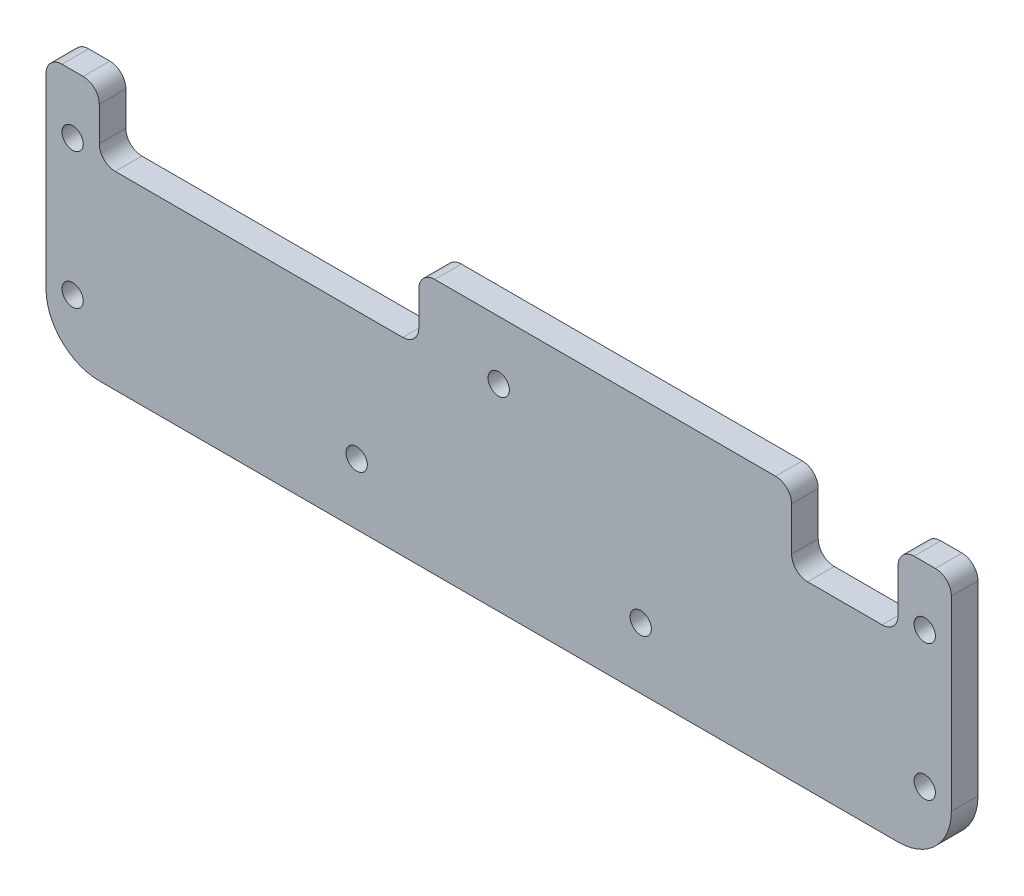
from build123d import *

# Parameters (mm, degrees)
SKETCH_1_R          = 2
EXTRUDE_1_DEPTH     = 5
SKETCH_2_W          = 60
SKETCH_2_H          = 24.578099901
SKETCH_2_W_2        = 20
SKETCH_2_H_2        = 18.209440524
CUT_EXTRUDE_1_DEPTH = 29
FILLET_1_R          = 3


with BuildPart() as part:
    # 草图1 → 凸台-拉伸1 (new body)
    with BuildSketch(Plane.XY):
        with BuildLine():
            Line((-85, 0), (85, 0))
            Line((85, 0), (85, -38))
            ThreePointArc((85, -38), (82.071067812, -45.071067812), (75, -48))
            Line((75, -48), (-75, -48))
            ThreePointArc((-75, -48), (-82.071067812, -45.071067812), (-85, -38))
            Line((-85, -38), (-85, 0))
        make_face()
        with Locations((-80, -11)):
            Circle(SKETCH_1_R, mode=Mode.SUBTRACT)
        with Locations((0, -11)):
            Circle(SKETCH_1_R, mode=Mode.SUBTRACT)
        with Locations((80, -11)):
            Circle(SKETCH_1_R, mode=Mode.SUBTRACT)
        with Locations((-80, -36.5)):
            Circle(SKETCH_1_R, mode=Mode.SUBTRACT)
        with Locations((80, -36.5)):
            Circle(SKETCH_1_R, mode=Mode.SUBTRACT)
        with Locations((-26.666666667, -36.5)):
            Circle(SKETCH_1_R, mode=Mode.SUBTRACT)
        with Locations((26.666666667, -36.5)):
            Circle(SKETCH_1_R, mode=Mode.SUBTRACT)
    extrude(amount=EXTRUDE_1_DEPTH)

    # 草图2 → 切除-拉伸1 (cut)
    with BuildSketch(Plane.XY):
        with Locations((-45, -0.145574748)):
            Rectangle(SKETCH_2_W, SKETCH_2_H)
        with Locations((65, -5.064712671)):
            Rectangle(SKETCH_2_W_2, SKETCH_2_H_2)
    extrude(amount=CUT_EXTRUDE_1_DEPTH, mode=Mode.SUBTRACT)

    # 圆角1
    fillet_1_edges = [part.edges().sort_by_distance(p)[0] for p in [
        (-85, 0, 2.5),
        (85, 0, 2.5),
        (55, 0, 2.5),
        (75, 0, 2.5),
        (-75, 0, 2.5),
        (-15, 0, 2.5),
        (-75, -12.434624699, 2.5),
        (-15, -12.434624699, 2.5),
        (55, -14.169432933, 2.5),
        (75, -14.169432933, 2.5),
    ]]
    fillet(fillet_1_edges, radius=FILLET_1_R)


solid = part.part
